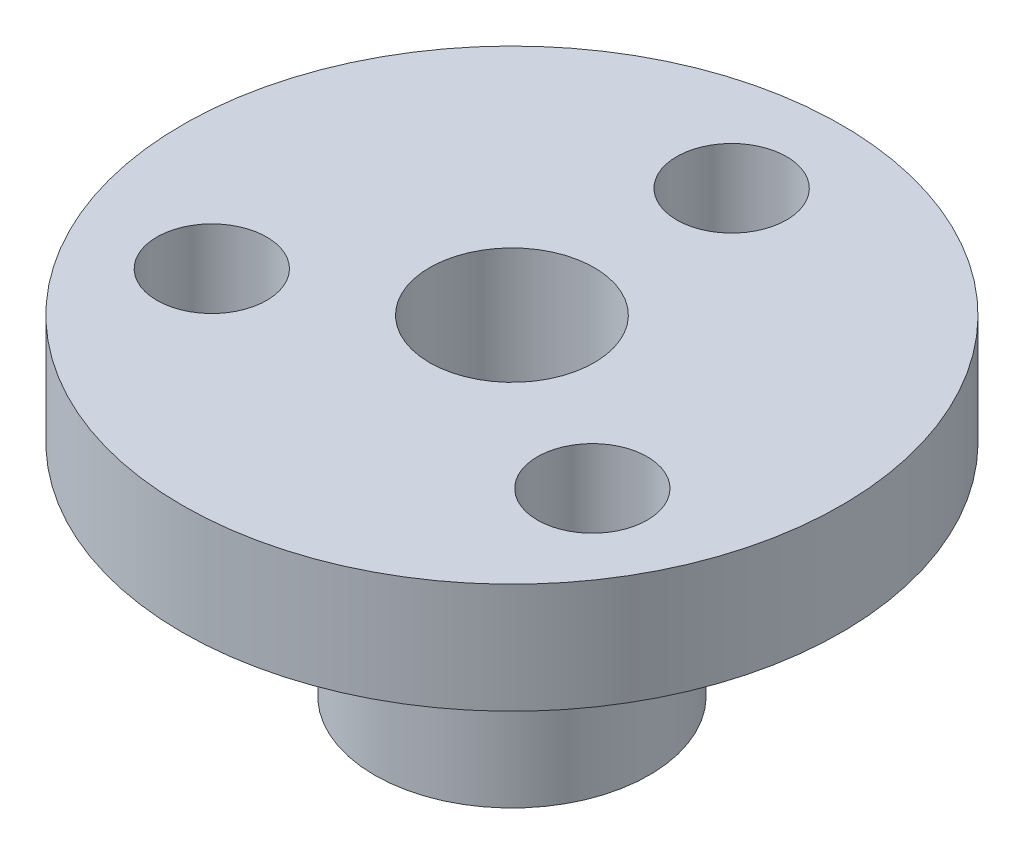
from build123d import *

# Parameters (mm, degrees)
SKETCH2_R          = 1.5875
CUT_EXTRUDE1_DEPTH = 10.53
CIRPATTERN1_COUNT  = 3


with BuildPart() as part:
    # Sketch1 → Revolve1 (revolve)
    with BuildSketch(Plane.XY):
        Polygon((2.38, 9.53), (9.525, 9.53), (9.525, 6.35), (3.97, 6.35), (3.97, 0), (2.38, 0), align=None)
    revolve(axis=Axis((0, 10.340432257, 0), (0, -1, 0)))

    # Sketch2 → Cut-Extrude1 (cut, through all)
    with BuildSketch(Plane(origin=(0, 9.53, 0), x_dir=(1, 0, 0), z_dir=(0, 1, 0))):
        with Locations((0, 6.35)):
            Circle(SKETCH2_R)
    cut_extrude1 = extrude(amount=-CUT_EXTRUDE1_DEPTH, mode=Mode.SUBTRACT)

    # CirPattern1: Cut-Extrude1 ×3 about axis
    cirpattern1_axis = Axis((0, 0, 0), (0, 1, 0))
    for i in range(1, CIRPATTERN1_COUNT):
        add(cut_extrude1.rotate(cirpattern1_axis, i * 360 / CIRPATTERN1_COUNT), mode=Mode.SUBTRACT)


solid = part.part
